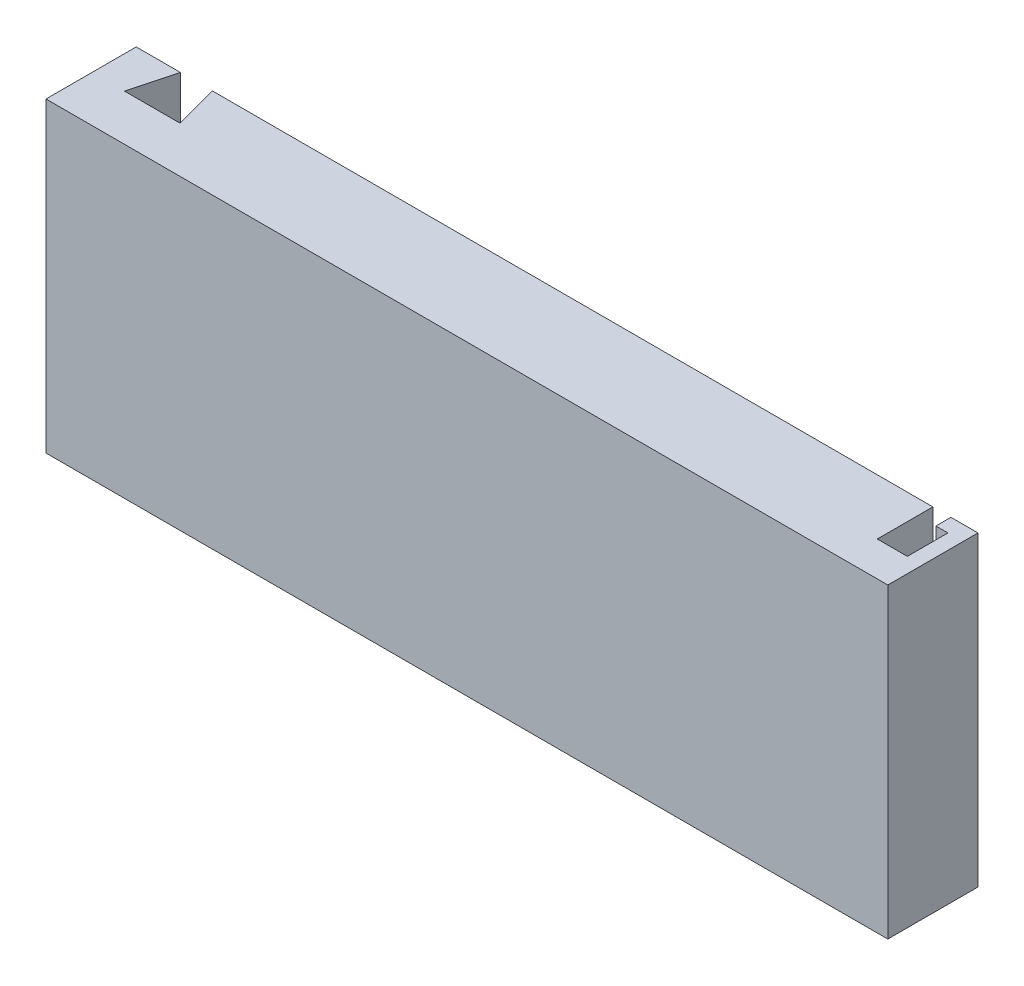
from build123d import *

# Parameters (mm, degrees)
SKETCH1_W               = 140
SKETCH1_H               = 51
BOSS_EXTRUDE1_DEPTH     = 15
CUT_EXTRUDE1_DEPTH      = 52
CUT_EXTRUDE2_DEPTH      = 1
CUT_EXTRUDE2_DEPTH_BACK = 26


with BuildPart() as part:
    # Sketch1 → Boss-Extrude1 (new body)
    with BuildSketch(Plane.XY):
        with Locations((9.063380282, 3.112676056)):
            Rectangle(SKETCH1_W, SKETCH1_H)
    extrude(amount=BOSS_EXTRUDE1_DEPTH)

    # Sketch2 → Cut-Extrude1 (cut, through all)
    with BuildSketch(Plane(origin=(0, 28.612676056, 0), x_dir=(1, 0, 0), z_dir=(0, 1, 0))):
        Polygon((74.563380282, -2.5), (74.563380282, 0), (71.563380282, 0), (71.563380282, -2.5), (71.563380282, -9.25), (76.563380282, -9.25), (76.563380282, -2.5), align=None)
    extrude(amount=-CUT_EXTRUDE1_DEPTH, mode=Mode.SUBTRACT)

    # Sketch3 → Cut-Extrude2 (cut, two sides)
    with BuildSketch(Plane(origin=(0, 28.612676056, 0), x_dir=(1, 0, 0), z_dir=(0, 1, 0))) as cut_extrude2_sk:
        Polygon((-352.539176525, 0), (-60.936619718, 0), (-53.586619718, 0), (-55.553644461, -7.34103628), (-46.319594976, -7.34103628), (-48.286619718, 0), (-123.75891502, 281.666440631), (-576.450550722, 649.359910128), (-805.230812226, 367.693469497), align=None)
    extrude(amount=CUT_EXTRUDE2_DEPTH, mode=Mode.SUBTRACT)
    extrude(cut_extrude2_sk.sketch, amount=-CUT_EXTRUDE2_DEPTH_BACK, mode=Mode.SUBTRACT)


solid = part.part
